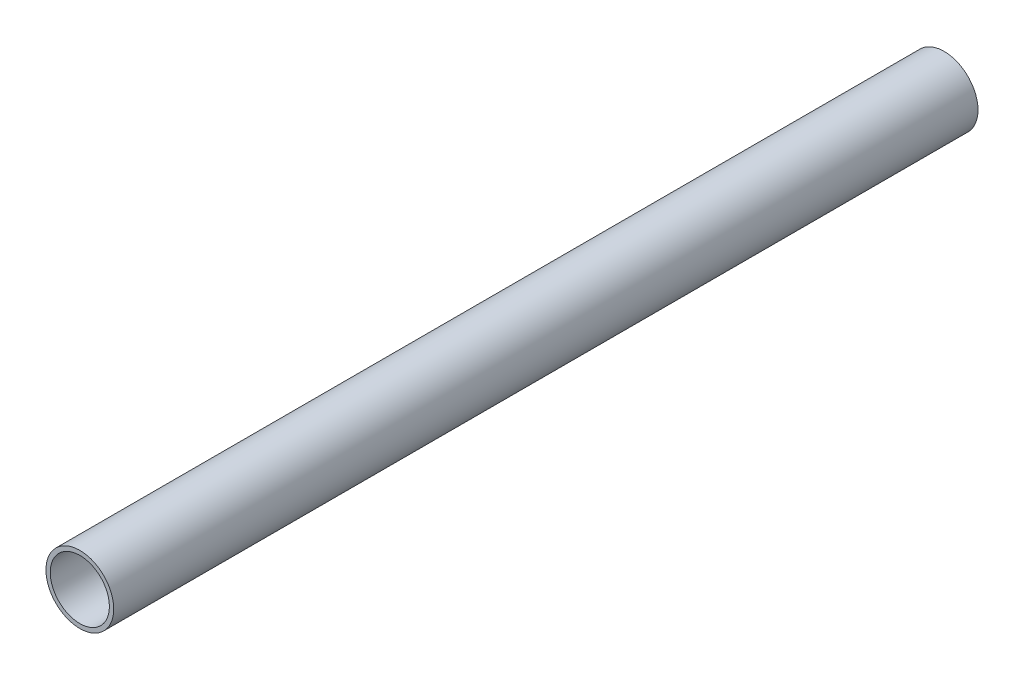
from build123d import *

# Parameters (mm, degrees)
SKETCH1_R           = 18.923
SKETCH1_R_2         = 16.51
BOSS_EXTRUDE1_DEPTH = 482.6


with BuildPart() as part:
    # Sketch1 → Boss-Extrude1 (new body)
    with BuildSketch(Plane.XY):
        Circle(SKETCH1_R)
        Circle(SKETCH1_R_2, mode=Mode.SUBTRACT)
    extrude(amount=BOSS_EXTRUDE1_DEPTH)


solid = part.part
